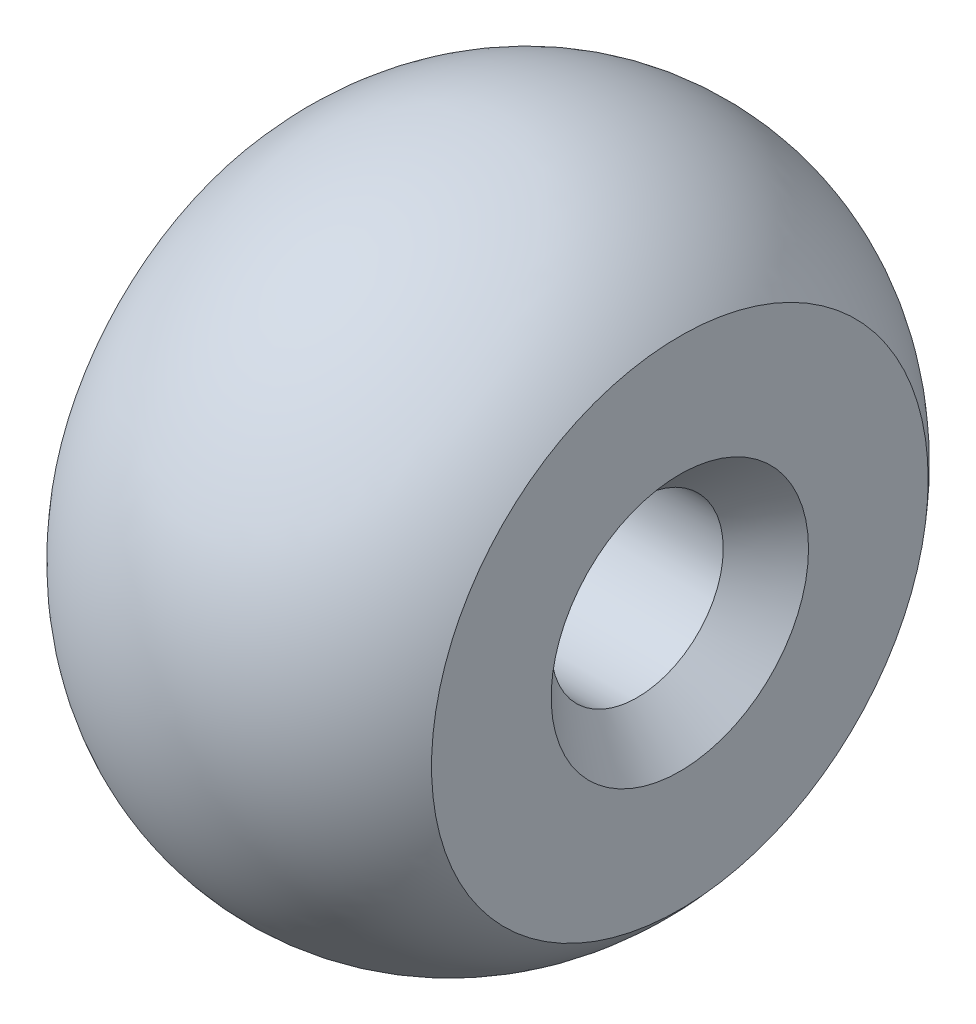
from build123d import *

# Parameters (mm, degrees)
PAH1_SIZE = 1


with BuildPart() as part:
    # Çizim1 → Döndür2 (revolve)
    with BuildSketch(Plane.XY):
        with BuildLine():
            Line((0, 4), (4.5, 4))
            Line((4.5, 4), (4.5, 7.806451613))
            ThreePointArc((4.5, 7.806451613), (0, 9.887560456), (-4.5, 7.806451613))
            Line((-4.5, 7.806451613), (-4.5, 4))
            Line((-4.5, 4), (0, 4))
        make_face()
    revolve(axis=Axis((0, 1.981811197, 0), (-1, 0, 0)))

    # Pah1
    pah1_edges = [part.edges().sort_by_distance(p)[0] for p in [
        (4.5, -0.036377607, 0),
    ]]
    chamfer(pah1_edges, length=PAH1_SIZE)


solid = part.part
